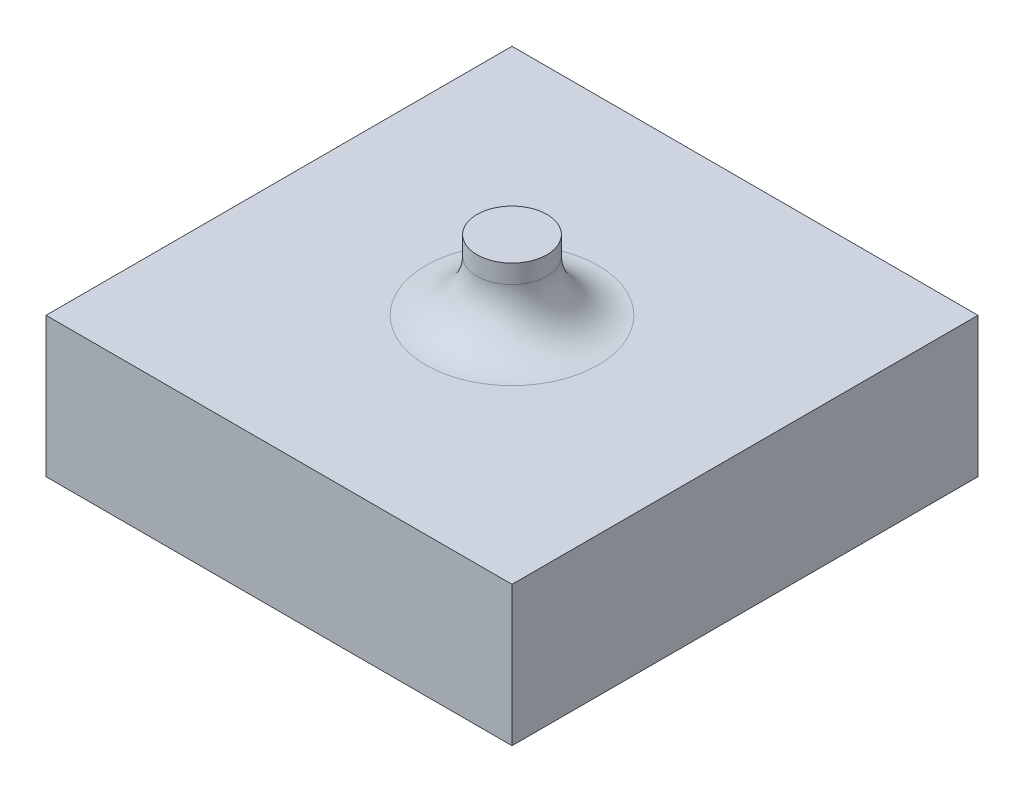
from build123d import *

# Parameters (mm, degrees)
SKETCH_1_W      = 10
SKETCH_1_H      = 10
EXTRUDE_1_DEPTH = 3
SKETCH_2_R      = 0.75
EXTRUDE_2_DEPTH = 1.5
FILLET_1_R      = 1.1


with BuildPart() as part:
    # 草图1 → 凸台-拉伸1 (new body)
    with BuildSketch(Plane(origin=(0, 0, 0), x_dir=(1, 0, 0), z_dir=(0, 1, 0))):
        Rectangle(SKETCH_1_W, SKETCH_1_H)
    extrude(amount=EXTRUDE_1_DEPTH)

    # 草图2 → 凸台-拉伸2 (add)
    with BuildSketch(Plane(origin=(0, 3, 0), x_dir=(1, 0, 0), z_dir=(0, 1, 0))):
        Circle(SKETCH_2_R)
    extrude(amount=EXTRUDE_2_DEPTH)

    # 圆角1
    fillet_1_edges = [part.edges().sort_by_distance(p)[0] for p in [
        (-0.75, 3, 0),
    ]]
    fillet(fillet_1_edges, radius=FILLET_1_R)


solid = part.part
